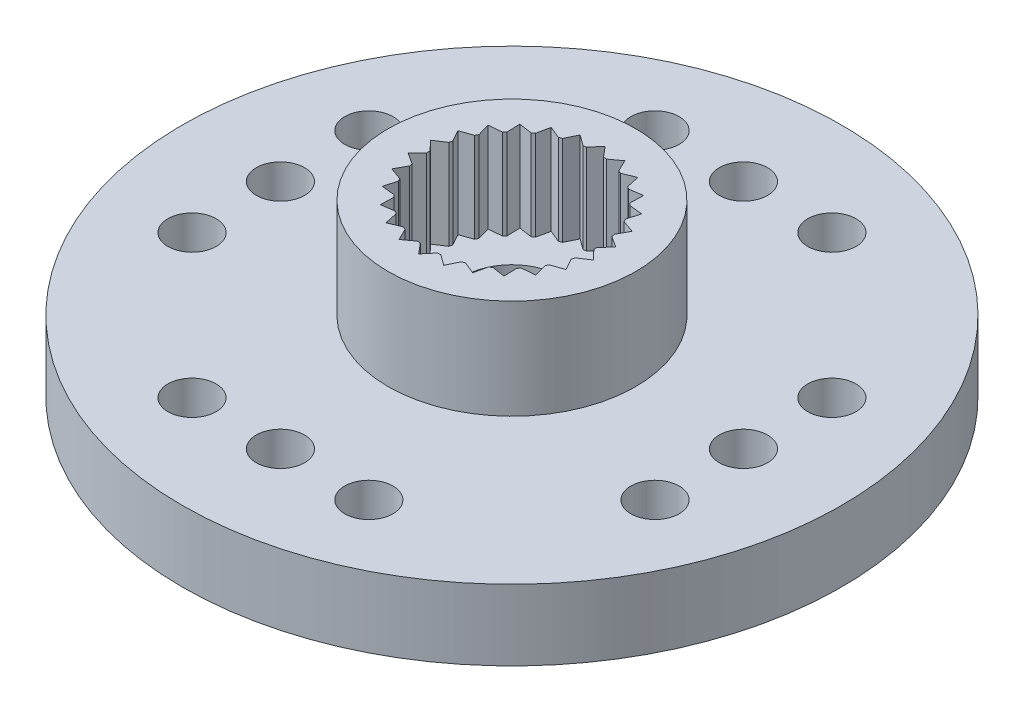
from build123d import *

# Parameters (mm, degrees)
SKETCH_1_R               = 10.25
EXTRUDE_1_DEPTH          = 2.2
SKETCH_2_R               = 3.85
SKETCH_2_R_2             = 2.6
EXTRUDE_2_DEPTH          = 3.1
SKETCH_3_R               = 0.75
SKETCH_3_R_2             = 1.5
CUT_EXTRUDE_1_DEPTH      = 3.2
SKETCH_4_R               = 4.25
SKETCH_4_R_2             = 3.25
SKETCH_4_R_3             = 3
SKETCH_4_R_4             = 1.5
CUT_EXTRUDE_2_DEPTH      = 1
SKETCH_5_R               = 2.6
SKETCH_5_R_2             = 1.5
EXTRUDE_3_DEPTH          = 0.3
CUT_EXTRUDE_3_DEPTH      = 2.8
PATTERN_CIRCULAR_1_COUNT = 26


with BuildPart() as part:
    # Эскиз1 → Бобышка-Вытянуть1 (new body)
    with BuildSketch(Plane(origin=(0, 0, 0), x_dir=(1, 0, 0), z_dir=(0, 1, 0))):
        Circle(SKETCH_1_R)
    extrude(amount=EXTRUDE_1_DEPTH)

    # Эскиз2 → Бобышка-Вытянуть2 (add)
    with BuildSketch(Plane(origin=(0, 2.2, 0), x_dir=(1, 0, 0), z_dir=(0, 1, 0))):
        Circle(SKETCH_2_R)
        Circle(SKETCH_2_R_2, mode=Mode.SUBTRACT)
    extrude(amount=EXTRUDE_2_DEPTH)

    # Эскиз3 → Вырез-Вытянуть1 (cut, through all)
    with BuildSketch(Plane(origin=(0, 2.2, 0), x_dir=(1, 0, 0), z_dir=(0, 1, 0))):
        with Locations((0, 7.2)):
            Circle(SKETCH_3_R)
        with Locations((7.2, 0)):
            Circle(SKETCH_3_R)
        with Locations((0, -7.2)):
            Circle(SKETCH_3_R)
        with Locations((-7.2, 0)):
            Circle(SKETCH_3_R)
        Circle(SKETCH_3_R_2)
        with Locations((2.75, 7.2)):
            Circle(SKETCH_3_R)
        with Locations((2.75, -7.2)):
            Circle(SKETCH_3_R)
        with Locations((-2.75, 7.2)):
            Circle(SKETCH_3_R)
        with Locations((-2.75, -7.2)):
            Circle(SKETCH_3_R)
        with Locations((7.2, 2.75)):
            Circle(SKETCH_3_R)
        with Locations((-7.2, 2.75)):
            Circle(SKETCH_3_R)
        with Locations((7.2, -2.75)):
            Circle(SKETCH_3_R)
        with Locations((-7.2, -2.75)):
            Circle(SKETCH_3_R)
    extrude(amount=-CUT_EXTRUDE_1_DEPTH, mode=Mode.SUBTRACT)

    # Эскиз4 → Вырез-Вытянуть2 (cut)
    with BuildSketch(Plane.XZ):
        Circle(SKETCH_4_R)
        Circle(SKETCH_4_R_2, mode=Mode.SUBTRACT)
        Circle(SKETCH_4_R_3)
        Circle(SKETCH_4_R_4, mode=Mode.SUBTRACT)
    extrude(amount=-CUT_EXTRUDE_2_DEPTH, mode=Mode.SUBTRACT)

    # Эскиз5 → Бобышка-Вытянуть3 (add)
    with BuildSketch(Plane(origin=(0, 2.2, 0), x_dir=(1, 0, 0), z_dir=(0, 1, 0))):
        Circle(SKETCH_5_R)
        Circle(SKETCH_5_R_2, mode=Mode.SUBTRACT)
    extrude(amount=EXTRUDE_3_DEPTH)

    # Эскиз6 → Вырез-Вытянуть3 (cut)
    with BuildSketch(Plane(origin=(0, 5.3, 0), x_dir=(1, 0, 0), z_dir=(0, 1, 0))):
        with BuildLine():
            Line((0, 2.9), (-0.262912611, 2.586672952))
            ThreePointArc((-0.262912611, 2.586672952), (0, 2.6), (0.262912611, 2.586672952))
            Line((0.262912611, 2.586672952), (0, 2.9))
        make_face()
    cut_extrude_3 = extrude(amount=-CUT_EXTRUDE_3_DEPTH, mode=Mode.SUBTRACT)

    # Круговой массив1: Вырез-Вытянуть3 ×26 about axis
    pattern_circular_1_axis = Axis((0, 0, 0), (0, 1, 0))
    for i in range(1, PATTERN_CIRCULAR_1_COUNT):
        add(cut_extrude_3.rotate(pattern_circular_1_axis, i * 360 / PATTERN_CIRCULAR_1_COUNT), mode=Mode.SUBTRACT)


solid = part.part
